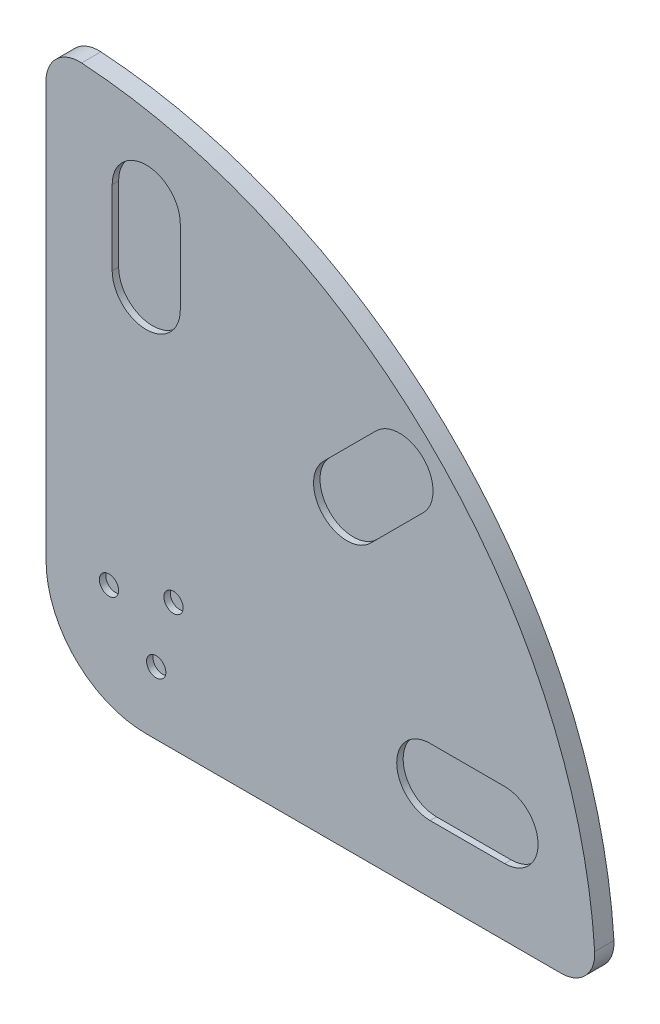
from build123d import *

# Parameters (mm, degrees)
Y_KSEKLIK_EKSTR_ZYON1_DEPTH = 15
IZIM2_R                     = 7.5
KES_EKSTR_ZYON1_DEPTH       = 5
RADYUS1_R                   = 26


with BuildPart() as part:
    # Çizim1 → Yükseklik-Ekstrüzyon1 (new body)
    with BuildSketch(Plane.XY):
        with BuildLine():
            Line((-78, 0), (-78, 350))
            ThreePointArc((-78, 350), (224.641702348, 224.641702348), (350, -78))
            Line((350, -78), (0, -78))
            ThreePointArc((0, -78), (-55.154328933, -55.154328933), (-78, 0))
        make_face()
    extrude(amount=Y_KSEKLIK_EKSTR_ZYON1_DEPTH)

    # Çizim2 → Kes-Ekstrüzyon1 (cut)
    with BuildSketch(Plane.XY.offset(15)):
        with Locations((21.213203436, 21.213203436)):
            Circle(IZIM2_R)
        with Locations((7.764571353, -28.977774789)):
            Circle(IZIM2_R)
        with Locations((-28.977774789, 7.764571353)):
            Circle(IZIM2_R)
        with BuildLine():
            Line((26.5, 279), (26.5, 221))
            ThreePointArc((26.5, 221), (0, 194.5), (-26.5, 221))
            Line((-26.5, 221), (-26.5, 279))
            ThreePointArc((-26.5, 279), (0, 305.5), (26.5, 279))
        make_face()
        with BuildLine():
            Line((215.667568262, 178.89801564), (174.655374953, 137.885822331))
            ThreePointArc((174.655374953, 137.885822331), (137.885822331, 137.885822331), (137.885822331, 174.655374953))
            Line((137.885822331, 174.655374953), (178.89801564, 215.667568262))
            ThreePointArc((178.89801564, 215.667568262), (215.667568262, 215.667568262), (215.667568262, 178.89801564))
        make_face()
        with BuildLine():
            Line((221, 26), (279, 26))
            ThreePointArc((279, 26), (305, 0), (279, -26))
            Line((279, -26), (221, -26))
            ThreePointArc((221, -26), (195, 0), (221, 26))
        make_face()
    extrude(amount=-KES_EKSTR_ZYON1_DEPTH, mode=Mode.SUBTRACT)

    # Radyus1
    radyus1_edges = [part.edges().sort_by_distance(p)[0] for p in [
        (-78, 350, 7.5),
        (350, -78, 7.5),
    ]]
    fillet(radyus1_edges, radius=RADYUS1_R)


solid = part.part
